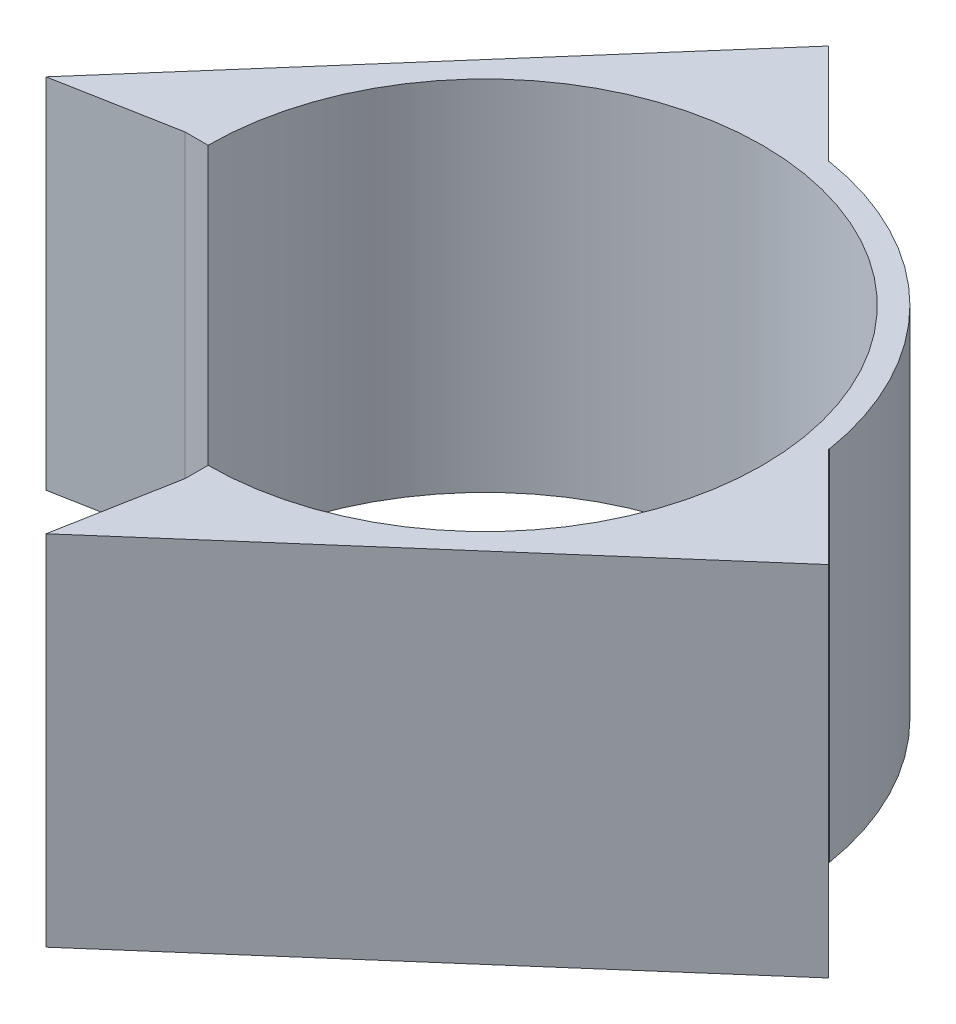
from build123d import *

# Parameters (mm, degrees)
BOSS_EXTRUDE1_DEPTH = 62
SKETCH3_W           = 15
SKETCH3_H           = 80.278098872
CUT_EXTRUDE1_DEPTH  = 24.5
SKETCH4_W           = 18.12750906
SKETCH4_H           = 69.709686178
CUT_EXTRUDE2_DEPTH  = 24.5


with BuildPart() as part:
    # Sketch1 → Boss-Extrude1 (new body)
    with BuildSketch(Plane(origin=(0, 0, 0), x_dir=(1, 0, 0), z_dir=(0, 1, 0))):
        with BuildLine():
            Line((-52.000074422, -0.000131195), (-48, -0.000131195))
            ThreePointArc((-48, -0.000131195), (33.941079112, 33.941171881), (0, -48))
            Line((0, -48), (0, -52.000074422))
            Line((0, -52.000074422), (-3.768119303, -72.286566827))
            Line((-3.768119303, -72.286566827), (68.579771311, -9.185198192))
            Line((68.579771311, -9.185198192), (75.652096433, -2.112870208))
            Line((75.652096433, -2.112870208), (58.450826977, 15.088392287))
            Line((58.450826977, 15.088392287), (51.378501856, 8.016064304))
            ThreePointArc((51.378501856, 8.016064304), (36.769597807, 36.769612685), (8.016043515, 51.378505099))
            Line((8.016043515, 51.378505099), (15.088368636, 58.450833083))
            Line((15.088368636, 58.450833083), (-2.112934166, 75.652128925))
            Line((-2.112934166, 75.652128925), (-9.185259288, 68.579800942))
            Line((-9.185259288, 68.579800942), (-72.286524075, -3.768180248))
            Line((-72.286524075, -3.768180248), (-52.000074422, -0.000131195))
        make_face()
    extrude(amount=BOSS_EXTRUDE1_DEPTH)

    # Sketch3 → Cut-Extrude1 (cut)
    with BuildSketch(Plane(origin=(38.882498626, 0, 38.882482893), x_dir=(0.707106638, 0, -0.707106924), z_dir=(0.707106924, 0, 0.707106638))):
        with Locations((49.498294294, 40.139049436)):
            Rectangle(SKETCH3_W, SKETCH3_H)
    extrude(amount=-CUT_EXTRUDE1_DEPTH, mode=Mode.SUBTRACT)

    # Sketch4 → Cut-Extrude2 (cut)
    with BuildSketch(Plane(origin=(-38.882531973, 0, -38.88251624), x_dir=(-0.707106638, 0, 0.707106924), z_dir=(-0.707106924, 0, -0.707106638))):
        with Locations((-51.062048824, 34.854843089)):
            Rectangle(SKETCH4_W, SKETCH4_H)
    extrude(amount=-CUT_EXTRUDE2_DEPTH, mode=Mode.SUBTRACT)


solid = part.part
